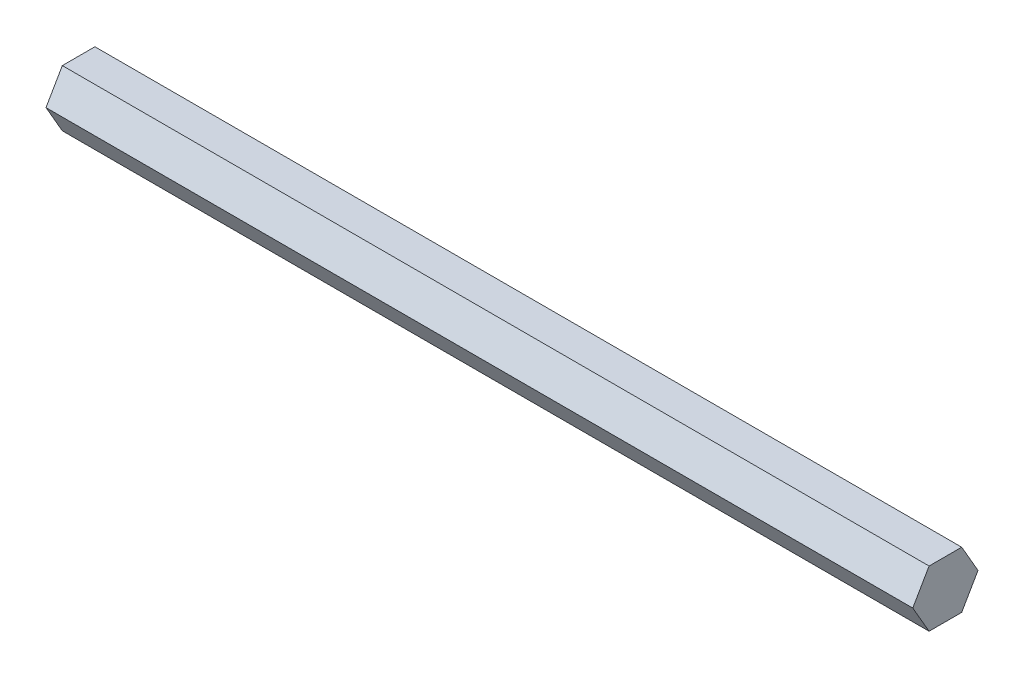
from build123d import *

# Parameters (mm, degrees)
BOSS_EXTRUDE1_DEPTH = 194.85


with BuildPart() as part:
    # Sketch1 → Boss-Extrude1 (new body)
    with BuildSketch(Plane(origin=(0, 0, 0), x_dir=(0, 0, -1), z_dir=(1, 0, 0))):
        Polygon((7.332348419, 0), (3.666174209, 6.35), (-3.666174209, 6.35), (-7.332348419, 0), (-3.666174209, -6.35), (3.666174209, -6.35), align=None)
    extrude(amount=BOSS_EXTRUDE1_DEPTH)


solid = part.part
